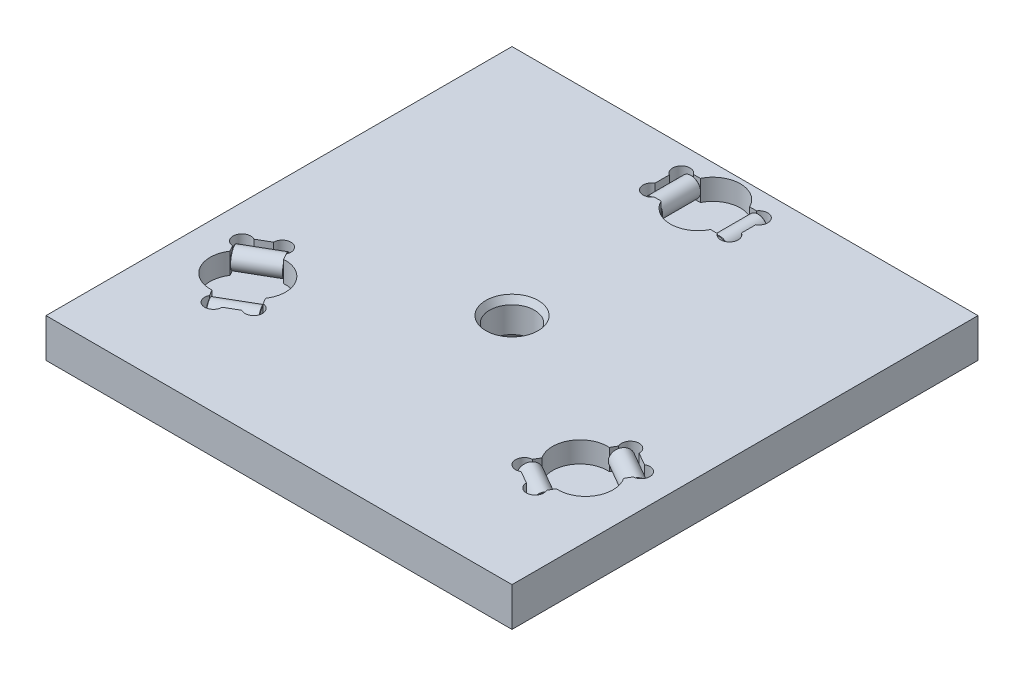
from build123d import *

# Parameters (mm, degrees)
SKETCH1_W           = 152.4
SKETCH1_H           = 152.4
EXTRUDE1_DEPTH      = 12.7
CUT_EXTRUDE1_DEPTH  = 6.858
CUT_EXTRUDE2_DEPTH  = 6.858
SKETCH10_R          = 3.175
EXTRUDE2_DEPTH      = 6.35
EXTRUDE2_2_DEPTH    = 6.35
CHAMFER1_SIZE       = 0.127
CHAMFER2_SIZE       = 0.127
CIRPATTERN4_COUNT   = 3
CIRPATTERN5_COUNT   = 3
SKETCH97_W          = 1.527820346
SKETCH97_H          = 0.474151141
CUT_EXTRUDE25_DEPTH = 0.0762


with BuildPart() as part:
    # Sketch1 → Extrude1 (new body)
    with BuildSketch(Plane(origin=(0, 0, 0), x_dir=(1, 0, 0), z_dir=(0, 1, 0))):
        Rectangle(SKETCH1_W, SKETCH1_H)
    extrude(amount=EXTRUDE1_DEPTH)

    # Sketch4 → 5_8-18 Tapped Hole1 (revolve, cut)
    with BuildSketch(Plane(origin=(0, 12.7, 0), x_dir=(0, 0, 1), z_dir=(1, 0, 0))):
        Polygon((0, 0), (0, 12.7), (8.5725, 12.7), (7.34187, 10.568486315), (7.34187, 2.131513685), (8.5725, 0), align=None)
    revolve(axis=Axis((0, 19.05, 0), (0, -1, 0)), mode=Mode.SUBTRACT)

    # Sketch8 → Cut-Extrude1 (cut)
    with BuildSketch(Plane(origin=(0, 12.7, 0), x_dir=(-1, 0, 0), z_dir=(0, 1, 0))):
        with BuildLine():
            Line((8.0645, -69.6595), (8.0645, -56.8325))
            ThreePointArc((8.0645, -56.8325), (0, -51.816), (-8.0645, -56.8325))
            Line((-8.0645, -56.8325), (-8.0645, -69.6595))
            ThreePointArc((-8.0645, -69.6595), (0, -74.676), (8.0645, -69.6595))
        make_face()
    cut_extrude1 = extrude(amount=-CUT_EXTRUDE1_DEPTH, mode=Mode.SUBTRACT)

    # Sketch9 → Cut-Extrude2 (cut)
    with BuildSketch(Plane(origin=(0, 12.7, 0), x_dir=(-1, 0, 0), z_dir=(0, 1, 0))):
        with BuildLine():
            Line((-14.12875, -65.597332409), (-14.12875, -60.894667591))
            ThreePointArc((-14.12875, -60.894667591), (-14.785569347, -56.466616589), (-10.324047559, -56.8325))
            Line((-10.324047559, -56.8325), (-8.0645, -56.8325))
            Line((-8.0645, -56.8325), (-8.0645, -69.6595))
            Line((-8.0645, -69.6595), (-10.324047559, -69.6595))
            ThreePointArc((-10.324047559, -69.6595), (-14.785569347, -70.025383411), (-14.12875, -65.597332409))
        make_face()
        with BuildLine():
            Line((8.0645, -69.6595), (8.0645, -56.8325))
            Line((8.0645, -56.8325), (10.324047559, -56.8325))
            ThreePointArc((10.324047559, -56.8325), (14.785569347, -56.466616589), (14.12875, -60.894667591))
            Line((14.12875, -60.894667591), (14.12875, -65.597332409))
            ThreePointArc((14.12875, -65.597332409), (14.785569347, -70.025383411), (10.324047559, -69.6595))
            Line((10.324047559, -69.6595), (8.0645, -69.6595))
        make_face()
    cut_extrude2 = extrude(amount=-CUT_EXTRUDE2_DEPTH, mode=Mode.SUBTRACT)

    # CirPattern4: Cut-Extrude1, Cut-Extrude2 ×3 about axis
    cirpattern4_axis = Axis((0, 0, 0), (0, 1, 0))
    add([cut_extrude1.rotate(cirpattern4_axis, i * 360 / CIRPATTERN4_COUNT) for i in range(1, CIRPATTERN4_COUNT)], mode=Mode.SUBTRACT)
    add([cut_extrude2.rotate(cirpattern4_axis, i * 360 / CIRPATTERN4_COUNT) for i in range(1, CIRPATTERN4_COUNT)], mode=Mode.SUBTRACT)

    # Sketch97 → Cut-Extrude25 (cut)
    with BuildSketch(Plane(origin=(0, 0, -76.2), x_dir=(-1, 0, 0), z_dir=(0, 0, -1))):
        with BuildLine():
            Line((26.420755292, 8.89), (26.420755292, 4.780690104))
            Line((26.420755292, 4.780690104), (24.882233618, 4.780690104))
            add(Edge.make_bspline(
                [(24.882233618, 4.780690104), (24.844080974, 4.780837069), (24.769634319, 4.781123838), (24.660924324, 4.78825798), (24.557977039, 4.798056689), (24.460529235, 4.810548566), (24.36921275, 4.82915713), (24.283295006, 4.850130709), (24.203220315, 4.875632264), (24.105418079, 4.914665889), (23.993025823, 4.974246047), (23.872899017, 5.064344499), (23.768273452, 5.171552892), (23.680770512, 5.294067497), (23.611648599, 5.426352035), (23.560749554, 5.563436916), (23.528667765, 5.703641399), (23.524997171, 5.798523221), (23.523164981, 5.845883815)],
                knots=[0, 0, 0, 0, 0.939347082, 1.832933197, 2.68146557, 3.486110826, 4.250749273, 4.975125432, 5.663232023, 6.31822681, 7.566717696, 8.783012481, 10.001501375, 11.241036602, 12.477233666, 13.665923641, 14.834937602, 16, 16, 16, 16], degree=3))
            add(Edge.make_bspline(
                [(23.523164981, 5.845883815), (23.525083146, 5.889950382), (23.528900984, 5.977658674), (23.559262965, 6.106861747), (23.60711274, 6.231953365), (23.674571031, 6.352075791), (23.760537279, 6.465437327), (23.869072255, 6.566315567), (23.995627783, 6.657033193), (24.090700893, 6.705160765), (24.139726101, 6.729978132)],
                knots=[0, 0, 0, 0, 0.9266367, 1.844339749, 2.778522519, 3.737737271, 4.73460122, 5.760014721, 6.844933715, 8, 8, 8, 8], degree=3))
            add(Edge.make_bspline(
                [(24.139726101, 6.729978132), (24.109409652, 6.739468376), (24.050055203, 6.758048659), (23.964728361, 6.792049377), (23.884627388, 6.830758713), (23.809601892, 6.874264218), (23.740072563, 6.922882375), (23.676695944, 6.976876442), (23.617711293, 7.034364659), (23.565098336, 7.097172521), (23.518211845, 7.163934323), (23.477000315, 7.233763871), (23.442230585, 7.306463207), (23.414226931, 7.382040444), (23.391742647, 7.460390746), (23.37629597, 7.541954145), (23.367134808, 7.626484486), (23.365795457, 7.683745432), (23.3651146, 7.712853936)],
                knots=[0, 0, 0, 0, 1.127307071, 2.207075445, 3.256908754, 4.282608941, 5.282408985, 6.263870425, 7.234983269, 8.202720022, 9.167413107, 10.127917746, 11.077645759, 12.02382113, 12.985756818, 13.967604811, 14.966835385, 16, 16, 16, 16], degree=3))
            add(Edge.make_bspline(
                [(23.3651146, 7.712853936), (23.366425397, 7.759604508), (23.369024823, 7.852314976), (23.393166075, 7.988060339), (23.429991714, 8.119232659), (23.482725098, 8.242690266), (23.54557159, 8.357267108), (23.616022198, 8.459754921), (23.693901717, 8.548372818), (23.780427729, 8.62285082), (23.876051679, 8.686242285), (23.981981501, 8.740367396), (24.098880125, 8.786539687), (24.227543031, 8.8243588), (24.369582121, 8.853926746), (24.525851845, 8.874604377), (24.697054593, 8.888161147), (24.816076581, 8.889369918), (24.878117723, 8.89)],
                knots=[0, 0, 0, 0, 1.028264767, 2.039138877, 3.0256281, 4.021796415, 4.986880544, 5.898364145, 6.754107619, 7.576323729, 8.403891453, 9.273758037, 10.190131768, 11.166715241, 12.222223064, 13.380548297, 14.634590339, 16, 16, 16, 16], degree=3))
            Line((24.878117723, 8.89), (26.420755292, 8.89))
        make_face()
        with BuildLine():
            Line((25.84123723, 6.519244291), (24.994185971, 6.519244291))
            add(Edge.make_bspline(
                [(24.994185971, 6.519244291), (24.966468345, 6.519134629), (24.913216524, 6.518923945), (24.836402041, 6.515986377), (24.765505955, 6.513480211), (24.700802502, 6.507189927), (24.641971135, 6.501028874), (24.589247291, 6.492735135), (24.542372725, 6.483389974), (24.513671421, 6.474721633), (24.500278532, 6.470676726)],
                knots=[0, 0, 0, 0, 1.335841395, 2.566453063, 3.705076039, 4.753984432, 5.69893722, 6.555639608, 7.326018133, 8, 8, 8, 8], degree=3))
            add(Edge.make_bspline(
                [(24.500278532, 6.470676726), (24.468797003, 6.459668671), (24.408107205, 6.438447445), (24.32680542, 6.389868761), (24.256795793, 6.332527084), (24.19985887, 6.263581733), (24.155980079, 6.185119142), (24.12429871, 6.097331853), (24.106580282, 5.999976239), (24.104013945, 5.932114161), (24.102683043, 5.896920917)],
                knots=[0, 0, 0, 0, 1.058475706, 2.04051966, 2.99494362, 3.924783233, 4.866712143, 5.841396942, 6.880549411, 8, 8, 8, 8], degree=3))
            add(Edge.make_bspline(
                [(24.102683043, 5.896920917), (24.103744246, 5.863100034), (24.105812408, 5.797187032), (24.123299049, 5.701206754), (24.153381261, 5.612060138), (24.192938274, 5.529158253), (24.245254172, 5.456442373), (24.307353512, 5.394031401), (24.381218327, 5.346138892), (24.450271627, 5.316473689), (24.512342955, 5.297883421), (24.567807503, 5.286889521), (24.630718929, 5.277200941), (24.701286553, 5.268964612), (24.779536339, 5.262572292), (24.865709616, 5.257494072), (24.959601183, 5.255337972), (25.024643094, 5.255010944), (25.058393938, 5.254841246)],
                knots=[0, 0, 0, 0, 1.215868667, 2.369587816, 3.493110624, 4.592136066, 5.660239876, 6.700065329, 7.740218573, 8.805446038, 9.392473349, 10.067987094, 10.837083945, 11.681746432, 12.622633381, 13.660583752, 14.786055431, 16, 16, 16, 16], degree=3))
            Line((25.058393938, 5.254841246), (25.84123723, 5.254841246))
            Line((25.84123723, 5.254841246), (25.84123723, 6.519244291))
        make_face(mode=Mode.SUBTRACT)
        with BuildLine():
            Line((25.84123723, 8.415848858), (24.869062753, 8.415848858))
            add(Edge.make_bspline(
                [(24.869062753, 8.415848858), (24.830361582, 8.415939328), (24.75924395, 8.416105578), (24.662143888, 8.411277868), (24.583346925, 8.407115819), (24.537557698, 8.399442758), (24.517565292, 8.396092561)],
                knots=[0, 0, 0, 0, 1.317202051, 2.420502769, 3.310362904, 4, 4, 4, 4], degree=3))
            add(Edge.make_bspline(
                [(24.517565292, 8.396092561), (24.488877381, 8.390073866), (24.433330168, 8.378420118), (24.354847985, 8.352144933), (24.282644159, 8.322665787), (24.218489521, 8.284795967), (24.159885333, 8.240552057), (24.108426377, 8.186257609), (24.060663133, 8.124084452), (24.020387589, 8.052679979), (23.986047846, 7.974663184), (23.962587574, 7.889537561), (23.947268969, 7.799017784), (23.945523425, 7.736516819), (23.944632662, 7.704622145)],
                knots=[0, 0, 0, 0, 1.067695626, 2.067334776, 3.013065832, 3.905220739, 4.775573709, 5.681088305, 6.623427354, 7.627212225, 8.662261666, 9.723046264, 10.838054812, 12, 12, 12, 12], degree=3))
            add(Edge.make_bspline(
                [(23.944632662, 7.704622145), (23.945776914, 7.66721077), (23.948008323, 7.59425477), (23.968883018, 7.488735043), (24.004157809, 7.391115544), (24.051293919, 7.301043397), (24.112399776, 7.221759571), (24.185202143, 7.154864467), (24.268906703, 7.100541273), (24.365720137, 7.058686655), (24.479150538, 7.02848369), (24.612171655, 7.008329419), (24.766723047, 6.995073478), (24.876988144, 6.993978739), (24.935740257, 6.993395433)],
                knots=[0, 0, 0, 0, 0.961406335, 1.874840495, 2.752092553, 3.623420628, 4.478799371, 5.312865821, 6.154540246, 7.033011991, 8.014031727, 9.164923062, 10.489397236, 12, 12, 12, 12], degree=3))
            Line((24.935740257, 6.993395433), (25.84123723, 6.993395433))
            Line((25.84123723, 6.993395433), (25.84123723, 8.415848858))
        make_face(mode=Mode.SUBTRACT)
        Polygon((23.189777459, 8.89), (21.558236551, 4.780690104), (20.904632373, 4.780690104), (19.273091465, 8.89), (19.888006227, 8.89), (20.355571936, 7.625596955), (22.107296988, 7.625596955), (22.574862697, 8.89), align=None)
        with BuildLine():
            Line((21.932783026, 7.151445813), (20.530085898, 7.151445813))
            Line((20.530085898, 7.151445813), (20.929327745, 6.071434879))
            add(Edge.make_bspline(
                [(20.929327745, 6.071434879), (20.944633252, 6.029704728), (20.974558408, 5.948114405), (21.019185831, 5.829570552), (21.059956726, 5.716996443), (21.099935936, 5.612006231), (21.136025884, 5.513074827), (21.169290913, 5.420870467), (21.202189747, 5.336034016), (21.2219328, 5.281220928), (21.231434462, 5.254841246)],
                knots=[0, 0, 0, 0, 1.225184869, 2.395467751, 3.491410812, 4.525364584, 5.492066482, 6.394148129, 7.227157926, 8, 8, 8, 8], degree=3))
            add(Edge.make_bspline(
                [(21.231434462, 5.254841246), (21.247190645, 5.319877723), (21.278829262, 5.450471796), (21.344235116, 5.641678626), (21.420282913, 5.830708302), (21.48136513, 5.952468973), (21.512138523, 6.013812345)],
                knots=[0, 0, 0, 0, 0.989154277, 1.986234384, 2.985459177, 4, 4, 4, 4], degree=3))
            Line((21.512138523, 6.013812345), (21.932783026, 7.151445813))
        make_face(mode=Mode.SUBTRACT)
        Polygon((18.834337023, 8.89), (18.834337023, 4.780690104), (18.25481896, 4.780690104), (18.25481896, 8.415848858), (16.305530933, 8.415848858), (16.305530933, 8.89), align=None)
        with Locations((15.225519999, 7.441204845)):
            Rectangle(SKETCH97_W, SKETCH97_H)
        Polygon((12.775739099, 8.89), (12.775739099, 5.254841246), (14.092825604, 5.254841246), (14.092825604, 4.780690104), (10.879134532, 4.780690104), (10.879134532, 5.254841246), (12.196221037, 5.254841246), (12.196221037, 8.89), align=None)
        Polygon((10.29961647, 8.89), (10.29961647, 4.780690104), (7.402026159, 4.780690104), (7.402026159, 5.254841246), (9.720098407, 5.254841246), (9.720098407, 6.519244291), (7.560076539, 6.519244291), (7.560076539, 6.993395433), (9.720098407, 6.993395433), (9.720098407, 8.415848858), (7.296659238, 8.415848858), (7.296659238, 8.89), align=None)
        with BuildLine():
            Line((3.714183944, 7.439558486), (3.134665882, 7.574559853))
            add(Edge.make_bspline(
                [(3.134665882, 7.574559853), (3.149184009, 7.628876821), (3.177583267, 7.735127552), (3.233739532, 7.887178222), (3.296740338, 8.029893584), (3.36823808, 8.16279463), (3.448456966, 8.285303502), (3.537046571, 8.39803532), (3.633993801, 8.501169334), (3.740042596, 8.593433147), (3.852431823, 8.6759567), (3.971948143, 8.746687593), (4.096471141, 8.808365112), (4.228037511, 8.857802991), (4.365681257, 8.895301307), (4.509059333, 8.922545218), (4.658520084, 8.939347167), (4.760400325, 8.941557415), (4.812304818, 8.94268346)],
                knots=[0, 0, 0, 0, 1.145367768, 2.240481511, 3.299486216, 4.322926322, 5.312543435, 6.280301985, 7.2416403, 8.192823262, 9.141388579, 10.079393599, 11.019812878, 11.970222822, 12.938950422, 13.923894909, 14.942295558, 16, 16, 16, 16], degree=3))
            add(Edge.make_bspline(
                [(4.812304818, 8.94268346), (4.86555733, 8.941899873), (4.969741613, 8.940366848), (5.122403811, 8.928193388), (5.267400772, 8.906355441), (5.405249268, 8.878421442), (5.534971691, 8.840071505), (5.657506899, 8.794322009), (5.771797453, 8.738930308), (5.879052839, 8.676088234), (5.97877009, 8.604657384), (6.073229181, 8.526610267), (6.160133711, 8.439786367), (6.2416575, 8.346238859), (6.316024696, 8.244732857), (6.385971347, 8.136647597), (6.448083381, 8.020078557), (6.504662626, 7.897186947), (6.554323439, 7.769162573), (6.598255888, 7.638534273), (6.634173067, 7.505041755), (6.66509544, 7.369808335), (6.687559046, 7.231696116), (6.705394453, 7.091741365), (6.715200719, 6.949086035), (6.71649112, 6.853194165), (6.717141176, 6.804887427)],
                knots=[0, 0, 0, 0, 1.180680974, 2.309907975, 3.39230657, 4.430402719, 5.425739985, 6.38846843, 7.327253855, 8.238163682, 9.141319901, 10.044148192, 10.951882972, 11.861898394, 12.79276478, 13.739539846, 14.714057202, 15.718574761, 16.737652364, 17.7573291, 18.772768038, 19.801551793, 20.831755737, 21.873891013, 22.928945814, 24, 24, 24, 24], degree=3))
            add(Edge.make_bspline(
                [(6.717141176, 6.804887427), (6.716211278, 6.752738413), (6.714374034, 6.649705134), (6.704007455, 6.497675536), (6.68495355, 6.350952204), (6.658540252, 6.209420917), (6.624888752, 6.072776527), (6.583920653, 5.940986776), (6.535047376, 5.814588284), (6.479541804, 5.693545144), (6.415697692, 5.57934203), (6.346990824, 5.470938673), (6.270599359, 5.370528083), (6.189326076, 5.275807022), (6.100078087, 5.189682203), (6.00491219, 5.110139411), (5.903678229, 5.03772562), (5.796543909, 4.972684763), (5.684843473, 4.915595068), (5.570431257, 4.86497965), (5.452864215, 4.822975321), (5.332435357, 4.788376353), (5.20930324, 4.761113884), (5.08331065, 4.742383268), (4.954669508, 4.730475643), (4.867758412, 4.728835601), (4.823829325, 4.728006644)],
                knots=[0, 0, 0, 0, 1.185683611, 2.342611346, 3.462256682, 4.54752026, 5.614193237, 6.659919581, 7.68288344, 8.693273043, 9.684551299, 10.655340776, 11.608553282, 12.550450986, 13.490114939, 14.424629326, 15.368095761, 16.317073336, 17.27126517, 18.21821065, 19.159447054, 20.107173046, 21.065292491, 22.024305098, 23.001387895, 24, 24, 24, 24], degree=3))
            add(Edge.make_bspline(
                [(4.823829325, 4.728006644), (4.774668486, 4.728889462), (4.678037988, 4.730624727), (4.536183906, 4.746247319), (4.399925352, 4.769118302), (4.270296994, 4.804526736), (4.14590919, 4.847570989), (4.028210019, 4.902613304), (3.915640033, 4.965678026), (3.810192854, 5.039477821), (3.711260027, 5.121480426), (3.62073695, 5.212719204), (3.536847812, 5.310718254), (3.462131215, 5.417977882), (3.393374419, 5.531881412), (3.334370796, 5.654868957), (3.281965495, 5.785124733), (3.254180554, 5.876110586), (3.240032802, 5.922439468)],
                knots=[0, 0, 0, 0, 1.098094218, 2.158412914, 3.185560839, 4.182001861, 5.157396189, 6.123029743, 7.081238243, 8.037090006, 8.994807998, 9.948592839, 10.905564776, 11.873472997, 12.866077505, 13.875170528, 14.918062841, 16, 16, 16, 16], degree=3))
            Line((3.240032802, 5.922439468), (3.819550865, 6.046739507))
            add(Edge.make_bspline(
                [(3.819550865, 6.046739507), (3.830930033, 6.011195101), (3.853202587, 5.9416237), (3.892778601, 5.842490464), (3.935413408, 5.750394652), (3.982516772, 5.66640255), (4.032618687, 5.589274308), (4.087060336, 5.519743005), (4.145683251, 5.457969499), (4.207591514, 5.402897412), (4.274308867, 5.356013412), (4.344412081, 5.3141759), (4.419562936, 5.280221305), (4.498039288, 5.25088412), (4.580752266, 5.228784122), (4.667480443, 5.213193281), (4.758332844, 5.204180438), (4.820242378, 5.20284095), (4.851817413, 5.202157786)],
                knots=[0, 0, 0, 0, 1.235448321, 2.418154634, 3.531842193, 4.593464837, 5.60397568, 6.574568355, 7.512901199, 8.420602914, 9.313080425, 10.209065825, 11.119673064, 12.039525284, 12.980625235, 13.950111628, 14.954518094, 16, 16, 16, 16], degree=3))
            add(Edge.make_bspline(
                [(4.851817413, 5.202157786), (4.888068461, 5.202684002), (4.959363575, 5.203718915), (5.064106508, 5.215037043), (5.164689169, 5.231725541), (5.260394127, 5.256686571), (5.351286495, 5.287909364), (5.437613842, 5.325943242), (5.519484249, 5.371372276), (5.596507921, 5.424211699), (5.668980561, 5.482198149), (5.734852914, 5.546295664), (5.796162076, 5.613997095), (5.852463912, 5.686201184), (5.901700162, 5.764399494), (5.946438684, 5.846696506), (5.984998582, 5.93405394), (6.028606837, 6.056564566), (6.071474966, 6.21466714), (6.109567518, 6.408016985), (6.133585927, 6.604249253), (6.136274539, 6.736222004), (6.137623114, 6.802417889)],
                knots=[0, 0, 0, 0, 0.93518376, 1.839230475, 2.715875874, 3.56435359, 4.38848637, 5.193784266, 5.995774969, 6.801072864, 7.601780706, 8.38807956, 9.17025402, 9.957795531, 10.747499049, 11.552298616, 12.373413868, 13.208937875, 14.906380835, 16.595160405, 18.29217494, 20, 20, 20, 20], degree=3))
            add(Edge.make_bspline(
                [(6.137623114, 6.802417889), (6.13595575, 6.885628853), (6.132716098, 7.047306), (6.105713702, 7.28162706), (6.059413682, 7.499526008), (6.006519309, 7.669701654), (5.952888162, 7.795300924), (5.909569169, 7.8832694), (5.860107668, 7.964668777), (5.805750379, 8.039964519), (5.745792867, 8.108936174), (5.681071556, 8.171950334), (5.611571703, 8.229613288), (5.536469875, 8.279225745), (5.458656815, 8.323277279), (5.379114467, 8.362448745), (5.297792749, 8.395578237), (5.214363562, 8.421313899), (5.129998476, 8.443553089), (5.043768296, 8.458080772), (4.955697611, 8.466279738), (4.896560324, 8.467775438), (4.866634636, 8.468532318)],
                knots=[0, 0, 0, 0, 2.106789595, 4.093447702, 5.961877135, 7.741838795, 8.594923949, 9.418404614, 10.222784382, 11.003898572, 11.767382914, 12.533928212, 13.289274593, 14.050510641, 14.809809739, 15.552522078, 16.294453915, 17.030636788, 17.76204935, 18.502287276, 19.24210112, 20, 20, 20, 20], degree=3))
            add(Edge.make_bspline(
                [(4.866634636, 8.468532318), (4.830922384, 8.467783424), (4.76037806, 8.466304092), (4.656951825, 8.453353345), (4.557247673, 8.434273522), (4.462486017, 8.404813785), (4.371346342, 8.368804299), (4.284538451, 8.324068337), (4.20193812, 8.271071102), (4.123544496, 8.210342544), (4.051089193, 8.140790312), (3.984215083, 8.063878308), (3.92288643, 7.979595046), (3.868404095, 7.886922263), (3.821239308, 7.78587651), (3.777938929, 7.677896956), (3.741742518, 7.561706229), (3.723502096, 7.48085929), (3.714183944, 7.439558486)],
                knots=[0, 0, 0, 0, 1.013280452, 2.001587178, 2.954741544, 3.891007537, 4.813763809, 5.733392028, 6.65811846, 7.596035232, 8.543572245, 9.504144266, 10.485644879, 11.498176693, 12.550315313, 13.648080895, 14.798517897, 16, 16, 16, 16], degree=3))
        make_face()
        Polygon((-3.924917785, 8.89), (-3.924917785, 4.780690104), (-4.504435847, 4.780690104), (-4.504435847, 6.674001955), (-6.397747698, 4.780690104), (-7.191292318, 4.780690104), (-5.474140787, 6.497841635), (-7.296659238, 8.89), (-6.582962988, 8.89), (-5.107002923, 6.865802678), (-4.504435847, 7.467546575), (-4.504435847, 8.89), align=None)
        with BuildLine():
            Line((-7.71812692, 8.89), (-7.71812692, 4.780690104))
            Line((-7.71812692, 4.780690104), (-9.227837326, 4.780690104))
            add(Edge.make_bspline(
                [(-9.227837326, 4.780690104), (-9.290414158, 4.781036766), (-9.407659583, 4.781686279), (-9.571765891, 4.789630408), (-9.712702796, 4.799199107), (-9.798092454, 4.813063775), (-9.836989835, 4.81937952)],
                knots=[0, 0, 0, 0, 1.22865439, 2.302035814, 3.226529761, 4, 4, 4, 4], degree=3))
            add(Edge.make_bspline(
                [(-9.836989835, 4.81937952), (-9.884473361, 4.828399572), (-9.976593792, 4.845898926), (-10.106254583, 4.89008742), (-10.225541858, 4.942014627), (-10.33272047, 5.007662314), (-10.428954916, 5.086158807), (-10.514560127, 5.178874735), (-10.590015701, 5.28567021), (-10.655895623, 5.404637085), (-10.708022812, 5.534112627), (-10.745973045, 5.671031597), (-10.769924201, 5.814311278), (-10.772472245, 5.912191839), (-10.773767612, 5.961952063)],
                knots=[0, 0, 0, 0, 1.070866676, 2.077535254, 3.03113373, 3.95186103, 4.855919725, 5.777612234, 6.742027648, 7.750020258, 8.78762473, 9.830233769, 10.896940781, 12, 12, 12, 12], degree=3))
            add(Edge.make_bspline(
                [(-10.773767612, 5.961952063), (-10.772860198, 6.004529814), (-10.771074813, 6.08830387), (-10.755744131, 6.211380129), (-10.731563995, 6.329784187), (-10.695497246, 6.442707223), (-10.651400503, 6.551464143), (-10.59584402, 6.654240171), (-10.530912331, 6.752357851), (-10.456511256, 6.845982601), (-10.368043213, 6.931951656), (-10.262806108, 7.005510889), (-10.141826125, 7.067207065), (-10.005256916, 7.118510553), (-9.851941973, 7.155764933), (-9.683738885, 7.1850581), (-9.499236335, 7.200829531), (-9.371097385, 7.20299961), (-9.304392979, 7.204129274)],
                knots=[0, 0, 0, 0, 0.928803062, 1.827470905, 2.702365172, 3.562150579, 4.410580959, 5.259792768, 6.106763965, 6.975510033, 7.86481326, 8.788506802, 9.766003746, 10.821436188, 11.964367758, 13.203725265, 14.544362639, 16, 16, 16, 16], degree=3))
            Line((-9.304392979, 7.204129274), (-8.297644982, 7.204129274))
            Line((-8.297644982, 7.204129274), (-8.297644982, 8.89))
            Line((-8.297644982, 8.89), (-7.71812692, 8.89))
        make_face()
        with BuildLine():
            Line((-8.297644982, 6.729978132), (-9.288752577, 6.729978132))
            add(Edge.make_bspline(
                [(-9.288752577, 6.729978132), (-9.328281001, 6.729314654), (-9.404428848, 6.728036526), (-9.514472571, 6.719184893), (-9.615417133, 6.703689808), (-9.707840674, 6.682599805), (-9.791057699, 6.654625265), (-9.865999536, 6.621181117), (-9.931545217, 6.580654249), (-9.98837272, 6.533906489), (-10.037134865, 6.48150672), (-10.079428092, 6.424366006), (-10.115085256, 6.362203248), (-10.143654431, 6.294897441), (-10.167265646, 6.223192758), (-10.182192161, 6.145727534), (-10.192527834, 6.063756816), (-10.193667597, 6.007261561), (-10.194249549, 5.978415645)],
                knots=[0, 0, 0, 0, 1.40421292, 2.705086056, 3.918275699, 5.029558377, 6.068365212, 7.032404237, 7.938575147, 8.797260087, 9.638618655, 10.474993364, 11.317706051, 12.177828306, 13.068718597, 13.993981992, 14.975747128, 16, 16, 16, 16], degree=3))
            add(Edge.make_bspline(
                [(-10.194249549, 5.978415645), (-10.193020366, 5.936585355), (-10.190638639, 5.855532859), (-10.166695464, 5.738877103), (-10.129044632, 5.631173817), (-10.075640731, 5.53423877), (-10.009594316, 5.450153286), (-9.934278045, 5.379485778), (-9.847713046, 5.325304342), (-9.784263147, 5.302555795), (-9.752202391, 5.291061125)],
                knots=[0, 0, 0, 0, 1.143451971, 2.215610693, 3.244091205, 4.255765529, 5.229231363, 6.159234871, 7.069875225, 8, 8, 8, 8], degree=3))
            add(Edge.make_bspline(
                [(-9.752202391, 5.291061125), (-9.740431762, 5.288182946), (-9.714853375, 5.281928465), (-9.672482978, 5.274829535), (-9.62337792, 5.268107479), (-9.567298839, 5.263647708), (-9.504757161, 5.259218588), (-9.43556169, 5.257176874), (-9.359554799, 5.255413415), (-9.30658953, 5.255037796), (-9.278874428, 5.254841246)],
                knots=[0, 0, 0, 0, 0.611063981, 1.327884044, 2.165719042, 3.110592661, 4.16481496, 5.328235826, 6.601947678, 8, 8, 8, 8], degree=3))
            Line((-9.278874428, 5.254841246), (-8.297644982, 5.254841246))
            Line((-8.297644982, 5.254841246), (-8.297644982, 6.729978132))
        make_face(mode=Mode.SUBTRACT)
        with Locations((-11.959145466, 7.441204845)):
            Rectangle(SKETCH97_W, SKETCH97_H)
        with BuildLine():
            Line((-15.778696331, 5.834359308), (-15.251861729, 5.887042768))
            add(Edge.make_bspline(
                [(-15.251861729, 5.887042768), (-15.240493062, 5.841732182), (-15.219093296, 5.756441976), (-15.174218188, 5.640758679), (-15.124766776, 5.542910286), (-15.081804247, 5.490221628), (-15.061707365, 5.465575087)],
                knots=[0, 0, 0, 0, 1.199207122, 2.257322842, 3.184815751, 4, 4, 4, 4], degree=3))
            add(Edge.make_bspline(
                [(-15.061707365, 5.465575087), (-15.044456529, 5.448764793), (-15.010528128, 5.415702835), (-14.954830043, 5.372606337), (-14.896115042, 5.336092822), (-14.834205665, 5.306511339), (-14.769436374, 5.283143666), (-14.701538881, 5.266796734), (-14.630667002, 5.256677056), (-14.582376668, 5.255458393), (-14.557921776, 5.254841246)],
                knots=[0, 0, 0, 0, 1.028360939, 2.022547923, 3.001693811, 3.976902288, 4.948369586, 5.937776631, 6.955661634, 8, 8, 8, 8], degree=3))
            add(Edge.make_bspline(
                [(-14.557921776, 5.254841246), (-14.51827619, 5.256117785), (-14.439938241, 5.258640169), (-14.32500247, 5.283334125), (-14.213367529, 5.320292568), (-14.144205556, 5.35775757), (-14.109289186, 5.376671748)],
                knots=[0, 0, 0, 0, 1.010336883, 1.996381556, 2.988474728, 4, 4, 4, 4], degree=3))
            add(Edge.make_bspline(
                [(-14.109289186, 5.376671748), (-14.074958756, 5.405126299), (-14.004486598, 5.463536685), (-13.912622164, 5.571084386), (-13.831023841, 5.696673799), (-13.769923765, 5.813657652), (-13.728068837, 5.919498963), (-13.698914686, 6.009484979), (-13.675735854, 6.109283542), (-13.655950995, 6.218075501), (-13.640788347, 6.336268475), (-13.628071208, 6.463865954), (-13.621047406, 6.601212851), (-13.619481771, 6.695946579), (-13.618674462, 6.744795355)],
                knots=[0, 0, 0, 0, 1.063396562, 2.182898711, 3.360648584, 4.635554171, 5.326740425, 6.076945788, 6.892323083, 7.771510239, 8.716835194, 9.737306867, 10.833258317, 12, 12, 12, 12], degree=3))
            add(Edge.make_bspline(
                [(-13.618674462, 6.744795355), (-13.64974504, 6.701168872), (-13.710567592, 6.615767369), (-13.817833711, 6.50369367), (-13.935674827, 6.409769198), (-14.062851375, 6.334148566), (-14.196272417, 6.275518689), (-14.33384277, 6.234807911), (-14.474249935, 6.207463615), (-14.56931784, 6.204590386), (-14.617190669, 6.20314353)],
                knots=[0, 0, 0, 0, 1.08413448, 2.122259381, 3.131196715, 4.128532876, 5.111902129, 6.075762527, 7.031022177, 8, 8, 8, 8], degree=3))
            add(Edge.make_bspline(
                [(-14.617190669, 6.20314353), (-14.658404232, 6.204249001), (-14.739829461, 6.206433071), (-14.859714157, 6.223841733), (-14.974488608, 6.2539613), (-15.085220911, 6.294141699), (-15.190447485, 6.347463835), (-15.291948368, 6.410896753), (-15.387492092, 6.487649572), (-15.47826656, 6.574009076), (-15.561336029, 6.669985497), (-15.633700972, 6.77380424), (-15.695490579, 6.884164083), (-15.744617788, 7.00174449), (-15.783547568, 7.126013781), (-15.811335382, 7.256899834), (-15.828062172, 7.39467374), (-15.830256951, 7.488627342), (-15.831379791, 7.536693616)],
                knots=[0, 0, 0, 0, 0.98160025, 1.939337942, 2.877944864, 3.804478064, 4.739961265, 5.683019169, 6.650831814, 7.654132266, 8.664499124, 9.669140276, 10.664058004, 11.671756914, 12.699296594, 13.762159139, 14.855129872, 16, 16, 16, 16], degree=3))
            add(Edge.make_bspline(
                [(-15.831379791, 7.536693616), (-15.829291092, 7.600201696), (-15.825160195, 7.725803941), (-15.793196279, 7.91056527), (-15.739858459, 8.087981371), (-15.679361971, 8.2296243), (-15.620111754, 8.336473958), (-15.572537606, 8.412716921), (-15.520184321, 8.48366227), (-15.464766085, 8.550589831), (-15.403865442, 8.611282903), (-15.340975905, 8.66873557), (-15.272604711, 8.719597073), (-15.201523059, 8.766760832), (-15.126277691, 8.807561054), (-15.048968272, 8.84409086), (-14.9688775, 8.874622278), (-14.88621983, 8.899107766), (-14.801366041, 8.919153806), (-14.713873096, 8.932973379), (-14.62394799, 8.941487144), (-14.563154409, 8.942281601), (-14.532403225, 8.94268346)],
                knots=[0, 0, 0, 0, 1.777706882, 3.515835744, 5.23207167, 6.95628682, 7.816020017, 8.65165611, 9.4707737, 10.283378767, 11.082060806, 11.8764812, 12.666355411, 13.46551777, 14.263312302, 15.060773764, 15.858457287, 16.660642738, 17.473247806, 18.298111139, 19.139134514, 20, 20, 20, 20], degree=3))
            add(Edge.make_bspline(
                [(-14.532403225, 8.94268346), (-14.480471566, 8.941239727), (-14.378624451, 8.938408314), (-14.229531459, 8.916761221), (-14.087806689, 8.880251557), (-13.953203283, 8.830187146), (-13.826012088, 8.765486579), (-13.706674245, 8.6855705), (-13.594676167, 8.591427822), (-13.489859594, 8.483010552), (-13.395172112, 8.357452094), (-13.31262616, 8.213583377), (-13.245012485, 8.05021008), (-13.187904525, 7.869371029), (-13.145623031, 7.669355437), (-13.113014791, 7.451455275), (-13.095863771, 7.214830729), (-13.093212639, 7.05104183), (-13.09183986, 6.966230524)],
                knots=[0, 0, 0, 0, 0.898449204, 1.762016875, 2.600428026, 3.426826527, 4.242280324, 5.064055083, 5.906691075, 6.769749479, 7.668135943, 8.621070442, 9.631748766, 10.722023185, 11.898351526, 13.165512303, 14.532277789, 16, 16, 16, 16], degree=3))
            add(Edge.make_bspline(
                [(-13.09183986, 6.966230524), (-13.092171026, 6.917934438), (-13.092824125, 6.822688469), (-13.097528009, 6.682391224), (-13.106802974, 6.547088742), (-13.118994141, 6.416957454), (-13.134701863, 6.291789044), (-13.153140178, 6.171664632), (-13.176664763, 6.056752343), (-13.202548622, 5.946798326), (-13.232575848, 5.841727083), (-13.26484378, 5.741406079), (-13.302293737, 5.646570334), (-13.342488514, 5.556645288), (-13.386227252, 5.471762688), (-13.432791544, 5.391596264), (-13.484264417, 5.317174363), (-13.521282861, 5.27055999), (-13.539649272, 5.247432634)],
                knots=[0, 0, 0, 0, 1.280444348, 2.525197649, 3.720942618, 4.875526429, 5.989898656, 7.065115415, 8.096622082, 9.098853712, 10.059152529, 10.993162051, 11.891531392, 12.760921141, 13.603603485, 14.422073071, 15.217123906, 16, 16, 16, 16], degree=3))
            add(Edge.make_bspline(
                [(-13.539649272, 5.247432634), (-13.572835371, 5.21010481), (-13.638248253, 5.136528203), (-13.750149128, 5.041484655), (-13.869388936, 4.960302843), (-13.99786941, 4.894714967), (-14.134608563, 4.843580553), (-14.27969212, 4.8064615), (-14.433524933, 4.784935011), (-14.538646289, 4.782128008), (-14.592495297, 4.780690104)],
                knots=[0, 0, 0, 0, 1.005002357, 1.980952959, 2.948226316, 3.90482984, 4.879026092, 5.883055346, 6.915583142, 8, 8, 8, 8], degree=3))
            add(Edge.make_bspline(
                [(-14.592495297, 4.780690104), (-14.632591863, 4.781398888), (-14.711364795, 4.78279135), (-14.826787246, 4.796152165), (-14.93657428, 4.818482763), (-15.040970421, 4.848604244), (-15.139368633, 4.888699781), (-15.232903329, 4.936217333), (-15.320624739, 4.993377962), (-15.401897807, 5.059400726), (-15.476923843, 5.13241406), (-15.544123619, 5.213031094), (-15.603243933, 5.300247062), (-15.65474711, 5.394243354), (-15.698172925, 5.494575022), (-15.733827677, 5.601673281), (-15.760927668, 5.715510608), (-15.772691344, 5.794193939), (-15.778696331, 5.834359308)],
                knots=[0, 0, 0, 0, 1.095988384, 2.15315746, 3.171326302, 4.156539379, 5.119213808, 6.072133135, 7.021027441, 7.975952916, 8.930907862, 9.879001051, 10.840359051, 11.807350428, 12.805278655, 13.825435679, 14.889953203, 16, 16, 16, 16], degree=3))
        make_face()
        with BuildLine():
            add(Edge.make_bspline(
                [(-13.618674462, 7.525992288), (-13.620147853, 7.567240654), (-13.623075291, 7.649195873), (-13.645178879, 7.770630502), (-13.68188193, 7.888943524), (-13.731469277, 8.003191557), (-13.793342972, 8.109539766), (-13.865930105, 8.204382866), (-13.949031495, 8.285233341), (-14.042096757, 8.35170407), (-14.143890571, 8.403346431), (-14.25295888, 8.442094439), (-14.370149784, 8.464449498), (-14.450814394, 8.467150822), (-14.492067451, 8.468532318)],
                knots=[0, 0, 0, 0, 1.034371533, 2.055163721, 3.085036369, 4.136219926, 5.172765015, 6.164074703, 7.123048089, 8.070464312, 9.021723619, 9.977430468, 10.965628467, 12, 12, 12, 12], degree=3))
            add(Edge.make_bspline(
                [(-14.492067451, 8.468532318), (-14.521471846, 8.467740695), (-14.578866624, 8.466195517), (-14.662878495, 8.454117673), (-14.742872565, 8.435863313), (-14.818473313, 8.407924756), (-14.89020728, 8.373724752), (-14.957717313, 8.330977009), (-15.021021773, 8.280879856), (-15.079437687, 8.223117892), (-15.132239983, 8.158893944), (-15.178116339, 8.088581398), (-15.218629954, 8.013342716), (-15.249102536, 7.931327391), (-15.273933315, 7.844636995), (-15.29218867, 7.752451726), (-15.302906487, 7.654665773), (-15.303991044, 7.587483409), (-15.304545189, 7.553157197)],
                knots=[0, 0, 0, 0, 1.023462019, 1.997707343, 2.950204755, 3.875082018, 4.798131411, 5.712685617, 6.65128003, 7.603921197, 8.567945975, 9.540503156, 10.523517238, 11.53671457, 12.580096959, 13.661292135, 14.805058716, 16, 16, 16, 16], degree=3))
            add(Edge.make_bspline(
                [(-15.304545189, 7.553157197), (-15.304031841, 7.520194028), (-15.303027924, 7.455730391), (-15.291709709, 7.361667743), (-15.275264725, 7.27273213), (-15.249792132, 7.189487491), (-15.219145429, 7.111449885), (-15.18076275, 7.03884705), (-15.135230705, 6.971746528), (-15.08264802, 6.910331322), (-15.024486616, 6.85495236), (-14.960067573, 6.807600419), (-14.89104525, 6.767392672), (-14.816935258, 6.733971599), (-14.737634724, 6.708554188), (-14.653188155, 6.690907705), (-14.564043673, 6.678598626), (-14.502812801, 6.677735986), (-14.471487975, 6.677294671)],
                knots=[0, 0, 0, 0, 1.155242457, 2.259222408, 3.317825484, 4.322358011, 5.306829979, 6.253722241, 7.195762508, 8.144412979, 9.083697585, 10.00547228, 10.941152501, 11.87999348, 12.850638972, 13.854618393, 14.902453872, 16, 16, 16, 16], degree=3))
            add(Edge.make_bspline(
                [(-14.471487975, 6.677294671), (-14.442355485, 6.677749418), (-14.384947145, 6.678645538), (-14.300761979, 6.691059313), (-14.219606644, 6.708709728), (-14.141889336, 6.734502538), (-14.067490769, 6.76721526), (-13.997281102, 6.808502142), (-13.929085876, 6.854886669), (-13.866494235, 6.910456601), (-13.80783248, 6.97041303), (-13.757655692, 7.036893805), (-13.71458058, 7.107166902), (-13.678714114, 7.181725446), (-13.651466591, 7.261314863), (-13.632971822, 7.345584496), (-13.621043015, 7.434281216), (-13.619476263, 7.494946306), (-13.618674462, 7.525992288)],
                knots=[0, 0, 0, 0, 1.03701548, 2.04353757, 3.025450354, 3.993097303, 4.955942005, 5.915106969, 6.891406964, 7.889250744, 8.89182446, 9.875341956, 10.849485896, 11.824610452, 12.817027865, 13.839237692, 14.894207727, 16, 16, 16, 16], degree=3))
        make_face(mode=Mode.SUBTRACT)
        with Locations((-17.016757646, 7.441204845)):
            Rectangle(SKETCH97_W, SKETCH97_H)
        with BuildLine():
            Line((-20.83630851, 5.834359308), (-20.309473908, 5.887042768))
            add(Edge.make_bspline(
                [(-20.309473908, 5.887042768), (-20.298105241, 5.841732182), (-20.276705476, 5.756441976), (-20.231830367, 5.640758679), (-20.182378955, 5.542910286), (-20.139416426, 5.490221628), (-20.119319544, 5.465575087)],
                knots=[0, 0, 0, 0, 1.199207122, 2.257322842, 3.184815751, 4, 4, 4, 4], degree=3))
            add(Edge.make_bspline(
                [(-20.119319544, 5.465575087), (-20.102068708, 5.448764793), (-20.068140308, 5.415702835), (-20.012442223, 5.372606337), (-19.953727222, 5.336092822), (-19.891817845, 5.306511339), (-19.827048554, 5.283143666), (-19.759151061, 5.266796734), (-19.688279182, 5.256677056), (-19.639988847, 5.255458393), (-19.615533956, 5.254841246)],
                knots=[0, 0, 0, 0, 1.028360939, 2.022547923, 3.001693811, 3.976902288, 4.948369586, 5.937776631, 6.955661634, 8, 8, 8, 8], degree=3))
            add(Edge.make_bspline(
                [(-19.615533956, 5.254841246), (-19.575888369, 5.256117785), (-19.497550421, 5.258640169), (-19.38261465, 5.283334125), (-19.270979708, 5.320292568), (-19.201817735, 5.35775757), (-19.166901365, 5.376671748)],
                knots=[0, 0, 0, 0, 1.010336883, 1.996381556, 2.988474728, 4, 4, 4, 4], degree=3))
            add(Edge.make_bspline(
                [(-19.166901365, 5.376671748), (-19.132570935, 5.405126299), (-19.062098777, 5.463536685), (-18.970234343, 5.571084386), (-18.88863602, 5.696673799), (-18.827535944, 5.813657652), (-18.785681016, 5.919498963), (-18.756526865, 6.009484979), (-18.733348034, 6.109283542), (-18.713563175, 6.218075501), (-18.698400527, 6.336268475), (-18.685683388, 6.463865954), (-18.678659585, 6.601212851), (-18.67709395, 6.695946579), (-18.676286642, 6.744795355)],
                knots=[0, 0, 0, 0, 1.063396562, 2.182898711, 3.360648584, 4.635554171, 5.326740425, 6.076945788, 6.892323083, 7.771510239, 8.716835194, 9.737306867, 10.833258317, 12, 12, 12, 12], degree=3))
            add(Edge.make_bspline(
                [(-18.676286642, 6.744795355), (-18.70735722, 6.701168872), (-18.768179772, 6.615767369), (-18.87544589, 6.50369367), (-18.993287006, 6.409769198), (-19.120463555, 6.334148566), (-19.253884597, 6.275518689), (-19.391454949, 6.234807911), (-19.531862114, 6.207463615), (-19.626930019, 6.204590386), (-19.674802849, 6.20314353)],
                knots=[0, 0, 0, 0, 1.08413448, 2.122259381, 3.131196715, 4.128532876, 5.111902129, 6.075762527, 7.031022177, 8, 8, 8, 8], degree=3))
            add(Edge.make_bspline(
                [(-19.674802849, 6.20314353), (-19.716016411, 6.204249001), (-19.797441641, 6.206433071), (-19.917326336, 6.223841733), (-20.032100787, 6.2539613), (-20.14283309, 6.294141699), (-20.248059664, 6.347463835), (-20.349560548, 6.410896753), (-20.445104272, 6.487649572), (-20.53587874, 6.574009076), (-20.618948209, 6.669985497), (-20.691313151, 6.77380424), (-20.753102758, 6.884164083), (-20.802229967, 7.00174449), (-20.841159747, 7.126013781), (-20.868947561, 7.256899834), (-20.885674352, 7.39467374), (-20.887869131, 7.488627342), (-20.88899197, 7.536693616)],
                knots=[0, 0, 0, 0, 0.98160025, 1.939337942, 2.877944864, 3.804478064, 4.739961265, 5.683019169, 6.650831814, 7.654132266, 8.664499124, 9.669140276, 10.664058004, 11.671756914, 12.699296594, 13.762159139, 14.855129872, 16, 16, 16, 16], degree=3))
            add(Edge.make_bspline(
                [(-20.88899197, 7.536693616), (-20.886903271, 7.600201696), (-20.882772375, 7.725803941), (-20.850808459, 7.91056527), (-20.797470638, 8.087981371), (-20.73697415, 8.2296243), (-20.677723934, 8.336473958), (-20.630149786, 8.412716921), (-20.5777965, 8.48366227), (-20.522378265, 8.550589831), (-20.461477621, 8.611282903), (-20.398588085, 8.66873557), (-20.33021689, 8.719597073), (-20.259135239, 8.766760832), (-20.183889871, 8.807561054), (-20.106580452, 8.84409086), (-20.026489679, 8.874622278), (-19.943832009, 8.899107766), (-19.858978221, 8.919153806), (-19.771485275, 8.932973379), (-19.68156017, 8.941487144), (-19.620766588, 8.942281601), (-19.590015405, 8.94268346)],
                knots=[0, 0, 0, 0, 1.777706882, 3.515835744, 5.23207167, 6.95628682, 7.816020017, 8.65165611, 9.4707737, 10.283378767, 11.082060806, 11.8764812, 12.666355411, 13.46551777, 14.263312302, 15.060773764, 15.858457287, 16.660642738, 17.473247806, 18.298111139, 19.139134514, 20, 20, 20, 20], degree=3))
            add(Edge.make_bspline(
                [(-19.590015405, 8.94268346), (-19.538083746, 8.941239727), (-19.43623663, 8.938408314), (-19.287143638, 8.916761221), (-19.145418869, 8.880251557), (-19.010815462, 8.830187146), (-18.883624267, 8.765486579), (-18.764286424, 8.6855705), (-18.652288347, 8.591427822), (-18.547471773, 8.483010552), (-18.452784292, 8.357452094), (-18.37023834, 8.213583377), (-18.302624664, 8.05021008), (-18.245516704, 7.869371029), (-18.20323521, 7.669355437), (-18.170626971, 7.451455275), (-18.153475951, 7.214830729), (-18.150824819, 7.05104183), (-18.14945204, 6.966230524)],
                knots=[0, 0, 0, 0, 0.898449204, 1.762016875, 2.600428026, 3.426826527, 4.242280324, 5.064055083, 5.906691075, 6.769749479, 7.668135943, 8.621070442, 9.631748766, 10.722023185, 11.898351526, 13.165512303, 14.532277789, 16, 16, 16, 16], degree=3))
            add(Edge.make_bspline(
                [(-18.14945204, 6.966230524), (-18.149783205, 6.917934438), (-18.150436305, 6.822688469), (-18.155140188, 6.682391224), (-18.164415154, 6.547088742), (-18.17660632, 6.416957454), (-18.192314042, 6.291789044), (-18.210752358, 6.171664632), (-18.234276943, 6.056752343), (-18.260160801, 5.946798326), (-18.290188027, 5.841727083), (-18.32245596, 5.741406079), (-18.359905916, 5.646570334), (-18.400100694, 5.556645288), (-18.443839431, 5.471762688), (-18.490403724, 5.391596264), (-18.541876596, 5.317174363), (-18.57889504, 5.27055999), (-18.597261452, 5.247432634)],
                knots=[0, 0, 0, 0, 1.280444348, 2.525197649, 3.720942618, 4.875526429, 5.989898656, 7.065115415, 8.096622082, 9.098853712, 10.059152529, 10.993162051, 11.891531392, 12.760921141, 13.603603485, 14.422073071, 15.217123906, 16, 16, 16, 16], degree=3))
            add(Edge.make_bspline(
                [(-18.597261452, 5.247432634), (-18.63044755, 5.21010481), (-18.695860432, 5.136528203), (-18.807761307, 5.041484655), (-18.927001116, 4.960302843), (-19.055481589, 4.894714967), (-19.192220743, 4.843580553), (-19.3373043, 4.8064615), (-19.491137112, 4.784935011), (-19.596258468, 4.782128008), (-19.650107477, 4.780690104)],
                knots=[0, 0, 0, 0, 1.005002357, 1.980952959, 2.948226316, 3.90482984, 4.879026092, 5.883055346, 6.915583142, 8, 8, 8, 8], degree=3))
            add(Edge.make_bspline(
                [(-19.650107477, 4.780690104), (-19.690204042, 4.781398888), (-19.768976974, 4.78279135), (-19.884399426, 4.796152165), (-19.99418646, 4.818482763), (-20.0985826, 4.848604244), (-20.196980812, 4.888699781), (-20.290515508, 4.936217333), (-20.378236918, 4.993377962), (-20.459509986, 5.059400726), (-20.534536022, 5.13241406), (-20.601735799, 5.213031094), (-20.660856112, 5.300247062), (-20.712359289, 5.394243354), (-20.755785105, 5.494575022), (-20.791439857, 5.601673281), (-20.818539848, 5.715510608), (-20.830303523, 5.794193939), (-20.83630851, 5.834359308)],
                knots=[0, 0, 0, 0, 1.095988384, 2.15315746, 3.171326302, 4.156539379, 5.119213808, 6.072133135, 7.021027441, 7.975952916, 8.930907862, 9.879001051, 10.840359051, 11.807350428, 12.805278655, 13.825435679, 14.889953203, 16, 16, 16, 16], degree=3))
        make_face()
        with BuildLine():
            add(Edge.make_bspline(
                [(-18.676286642, 7.525992288), (-18.677760032, 7.567240654), (-18.680687471, 7.649195873), (-18.702791058, 7.770630502), (-18.739494109, 7.888943524), (-18.789081457, 8.003191557), (-18.850955151, 8.109539766), (-18.923542285, 8.204382866), (-19.006643675, 8.285233341), (-19.099708936, 8.35170407), (-19.20150275, 8.403346431), (-19.31057106, 8.442094439), (-19.427761963, 8.464449498), (-19.508426573, 8.467150822), (-19.549679631, 8.468532318)],
                knots=[0, 0, 0, 0, 1.034371533, 2.055163721, 3.085036369, 4.136219926, 5.172765015, 6.164074703, 7.123048089, 8.070464312, 9.021723619, 9.977430468, 10.965628467, 12, 12, 12, 12], degree=3))
            add(Edge.make_bspline(
                [(-19.549679631, 8.468532318), (-19.579084025, 8.467740695), (-19.636478804, 8.466195517), (-19.720490674, 8.454117673), (-19.800484745, 8.435863313), (-19.876085493, 8.407924756), (-19.947819459, 8.373724752), (-20.015329493, 8.330977009), (-20.078633953, 8.280879856), (-20.137049867, 8.223117892), (-20.189852163, 8.158893944), (-20.235728519, 8.088581398), (-20.276242133, 8.013342716), (-20.306714715, 7.931327391), (-20.331545495, 7.844636995), (-20.34980085, 7.752451726), (-20.360518666, 7.654665773), (-20.361603224, 7.587483409), (-20.362157368, 7.553157197)],
                knots=[0, 0, 0, 0, 1.023462019, 1.997707343, 2.950204755, 3.875082018, 4.798131411, 5.712685617, 6.65128003, 7.603921197, 8.567945975, 9.540503156, 10.523517238, 11.53671457, 12.580096959, 13.661292135, 14.805058716, 16, 16, 16, 16], degree=3))
            add(Edge.make_bspline(
                [(-20.362157368, 7.553157197), (-20.36164402, 7.520194028), (-20.360640103, 7.455730391), (-20.349321888, 7.361667743), (-20.332876904, 7.27273213), (-20.307404312, 7.189487491), (-20.276757609, 7.111449885), (-20.238374929, 7.03884705), (-20.192842884, 6.971746528), (-20.140260199, 6.910331322), (-20.082098796, 6.85495236), (-20.017679752, 6.807600419), (-19.94865743, 6.767392672), (-19.874547438, 6.733971599), (-19.795246904, 6.708554188), (-19.710800334, 6.690907705), (-19.621655852, 6.678598626), (-19.56042498, 6.677735986), (-19.529100154, 6.677294671)],
                knots=[0, 0, 0, 0, 1.155242457, 2.259222408, 3.317825484, 4.322358011, 5.306829979, 6.253722241, 7.195762508, 8.144412979, 9.083697585, 10.00547228, 10.941152501, 11.87999348, 12.850638972, 13.854618393, 14.902453872, 16, 16, 16, 16], degree=3))
            add(Edge.make_bspline(
                [(-19.529100154, 6.677294671), (-19.499967664, 6.677749418), (-19.442559325, 6.678645538), (-19.358374158, 6.691059313), (-19.277218823, 6.708709728), (-19.199501515, 6.734502538), (-19.125102948, 6.76721526), (-19.054893281, 6.808502142), (-18.986698055, 6.854886669), (-18.924106414, 6.910456601), (-18.86544466, 6.97041303), (-18.815267871, 7.036893805), (-18.77219276, 7.107166902), (-18.736326293, 7.181725446), (-18.70907877, 7.261314863), (-18.690584001, 7.345584496), (-18.678655194, 7.434281216), (-18.677088443, 7.494946306), (-18.676286642, 7.525992288)],
                knots=[0, 0, 0, 0, 1.03701548, 2.04353757, 3.025450354, 3.993097303, 4.955942005, 5.915106969, 6.891406964, 7.889250744, 8.89182446, 9.875341956, 10.849485896, 11.824610452, 12.817027865, 13.839237692, 14.894207727, 16, 16, 16, 16], degree=3))
        make_face(mode=Mode.SUBTRACT)
        with Locations((-22.074369825, 7.441204845)):
            Rectangle(SKETCH97_W, SKETCH97_H)
        with BuildLine():
            Line((-23.523164981, 8.89), (-23.523164981, 4.780690104))
            Line((-23.523164981, 4.780690104), (-25.032875387, 4.780690104))
            add(Edge.make_bspline(
                [(-25.032875387, 4.780690104), (-25.095452219, 4.781036766), (-25.212697644, 4.781686279), (-25.376803952, 4.789630408), (-25.517740857, 4.799199107), (-25.603130515, 4.813063775), (-25.642027896, 4.81937952)],
                knots=[0, 0, 0, 0, 1.22865439, 2.302035814, 3.226529761, 4, 4, 4, 4], degree=3))
            add(Edge.make_bspline(
                [(-25.642027896, 4.81937952), (-25.689511422, 4.828399572), (-25.781631853, 4.845898926), (-25.911292644, 4.89008742), (-26.030579919, 4.942014627), (-26.137758531, 5.007662314), (-26.233992977, 5.086158807), (-26.319598188, 5.178874735), (-26.395053762, 5.28567021), (-26.460933683, 5.404637085), (-26.513060873, 5.534112627), (-26.551011106, 5.671031597), (-26.574962262, 5.814311278), (-26.577510306, 5.912191839), (-26.578805672, 5.961952063)],
                knots=[0, 0, 0, 0, 1.070866676, 2.077535254, 3.03113373, 3.95186103, 4.855919725, 5.777612234, 6.742027648, 7.750020258, 8.78762473, 9.830233769, 10.896940781, 12, 12, 12, 12], degree=3))
            add(Edge.make_bspline(
                [(-26.578805672, 5.961952063), (-26.577898259, 6.004529814), (-26.576112874, 6.08830387), (-26.560782191, 6.211380129), (-26.536602056, 6.329784187), (-26.500535307, 6.442707223), (-26.456438563, 6.551464143), (-26.400882081, 6.654240171), (-26.335950392, 6.752357851), (-26.261549317, 6.845982601), (-26.173081274, 6.931951656), (-26.067844168, 7.005510889), (-25.946864186, 7.067207065), (-25.810294977, 7.118510553), (-25.656980033, 7.155764933), (-25.488776946, 7.1850581), (-25.304274395, 7.200829531), (-25.176135445, 7.20299961), (-25.10943104, 7.204129274)],
                knots=[0, 0, 0, 0, 0.928803062, 1.827470905, 2.702365172, 3.562150579, 4.410580959, 5.259792768, 6.106763965, 6.975510033, 7.86481326, 8.788506802, 9.766003746, 10.821436188, 11.964367758, 13.203725265, 14.544362639, 16, 16, 16, 16], degree=3))
            Line((-25.10943104, 7.204129274), (-24.102683043, 7.204129274))
            Line((-24.102683043, 7.204129274), (-24.102683043, 8.89))
            Line((-24.102683043, 8.89), (-23.523164981, 8.89))
        make_face()
        with BuildLine():
            Line((-24.102683043, 6.729978132), (-25.093790638, 6.729978132))
            add(Edge.make_bspline(
                [(-25.093790638, 6.729978132), (-25.133319062, 6.729314654), (-25.209466909, 6.728036526), (-25.319510631, 6.719184893), (-25.420455194, 6.703689808), (-25.512878735, 6.682599805), (-25.59609576, 6.654625265), (-25.671037597, 6.621181117), (-25.736583278, 6.580654249), (-25.793410781, 6.533906489), (-25.842172926, 6.48150672), (-25.884466153, 6.424366006), (-25.920123317, 6.362203248), (-25.948692492, 6.294897441), (-25.972303707, 6.223192758), (-25.987230222, 6.145727534), (-25.997565895, 6.063756816), (-25.998705658, 6.007261561), (-25.99928761, 5.978415645)],
                knots=[0, 0, 0, 0, 1.40421292, 2.705086056, 3.918275699, 5.029558377, 6.068365212, 7.032404237, 7.938575147, 8.797260087, 9.638618655, 10.474993364, 11.317706051, 12.177828306, 13.068718597, 13.993981992, 14.975747128, 16, 16, 16, 16], degree=3))
            add(Edge.make_bspline(
                [(-25.99928761, 5.978415645), (-25.998058427, 5.936585355), (-25.9956767, 5.855532859), (-25.971733525, 5.738877103), (-25.934082693, 5.631173817), (-25.880678792, 5.53423877), (-25.814632377, 5.450153286), (-25.739316106, 5.379485778), (-25.652751107, 5.325304342), (-25.589301208, 5.302555795), (-25.557240452, 5.291061125)],
                knots=[0, 0, 0, 0, 1.143451971, 2.215610693, 3.244091205, 4.255765529, 5.229231363, 6.159234871, 7.069875225, 8, 8, 8, 8], degree=3))
            add(Edge.make_bspline(
                [(-25.557240452, 5.291061125), (-25.545469823, 5.288182946), (-25.519891436, 5.281928465), (-25.477521039, 5.274829535), (-25.428415981, 5.268107479), (-25.3723369, 5.263647708), (-25.309795222, 5.259218588), (-25.240599751, 5.257176874), (-25.16459286, 5.255413415), (-25.111627591, 5.255037796), (-25.083912489, 5.254841246)],
                knots=[0, 0, 0, 0, 0.611063981, 1.327884044, 2.165719042, 3.110592661, 4.16481496, 5.328235826, 6.601947678, 8, 8, 8, 8], degree=3))
            Line((-25.083912489, 5.254841246), (-24.102683043, 5.254841246))
            Line((-24.102683043, 5.254841246), (-24.102683043, 6.729978132))
        make_face(mode=Mode.SUBTRACT)
    extrude(amount=-CUT_EXTRUDE25_DEPTH, mode=Mode.SUBTRACT)


with BuildPart() as body_2:
    # Sketch10 → Extrude2 (new body, symmetric)
    with BuildSketch(Plane.XY.offset(-63.246)):
        with Locations((10.95375, 9.017)):
            Circle(SKETCH10_R)
    extrude(amount=EXTRUDE2_DEPTH, both=True)

    # Chamfer2
    chamfer2_edges = [body_2.edges().sort_by_distance(p)[0] for p in [
        (7.77875, 9.017, -69.596),
        (7.77875, 9.017, -56.896),
    ]]
    chamfer(chamfer2_edges, length=CHAMFER2_SIZE)


with BuildPart() as body_3:
    # Sketch10 → Extrude2 2 (new body, symmetric)
    with BuildSketch(Plane.XY.offset(-63.246)):
        with Locations(Location((-10.95375, 9.017, 0), (0, 0, 180))):  # turned: the seam where the file's is
            Circle(SKETCH10_R)
    extrude(amount=EXTRUDE2_2_DEPTH, both=True)

    # Chamfer1
    chamfer1_edges = [body_3.edges().sort_by_distance(p)[0] for p in [
        (-7.77875, 9.017, -69.596),
        (-7.77875, 9.017, -56.896),
    ]]
    chamfer(chamfer1_edges, length=CHAMFER1_SIZE)


with BuildPart() as cirpattern5_1:
    # CirPattern5: pattern copy
    add(body_2.part.rotate(Axis((0, 0, 0), (0, 1, 0)), 1 * 360 / CIRPATTERN5_COUNT))


with BuildPart() as cirpattern5_2:
    # CirPattern5: pattern copy
    add(body_2.part.rotate(Axis((0, 0, 0), (0, 1, 0)), 2 * 360 / CIRPATTERN5_COUNT))


with BuildPart() as cirpattern5_3:
    # CirPattern5: pattern copy
    add(body_3.part.rotate(Axis((0, 0, 0), (0, 1, 0)), 1 * 360 / CIRPATTERN5_COUNT))


with BuildPart() as cirpattern5_4:
    # CirPattern5: pattern copy
    add(body_3.part.rotate(Axis((0, 0, 0), (0, 1, 0)), 2 * 360 / CIRPATTERN5_COUNT))


solid = Compound([part.part, body_2.part, body_3.part, cirpattern5_1.part, cirpattern5_2.part, cirpattern5_3.part, cirpattern5_4.part])
